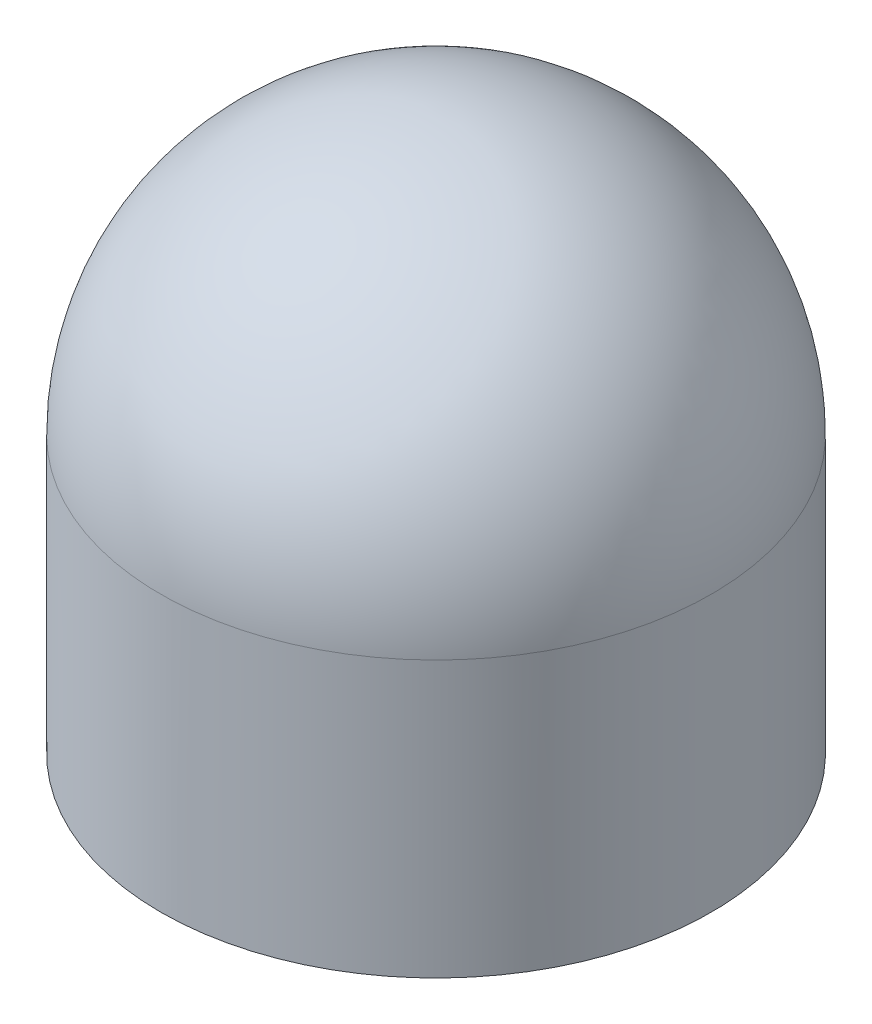
from build123d import *

# Parameters (mm, degrees)
ESQUISSE1_R      = 2.5
EXTRUSION1_DEPTH = 5
CONG_1_R         = 2.5


with BuildPart() as part:
    # Esquisse1 → Extrusion1 (new body)
    with BuildSketch(Plane(origin=(0, 0, 0), x_dir=(1, 0, 0), z_dir=(0, 1, 0))):
        Circle(ESQUISSE1_R)
    extrude(amount=EXTRUSION1_DEPTH)

    # Congé1
    cong_1_edges = [part.edges().sort_by_distance(p)[0] for p in [
        (-2.5, 5, 0),
    ]]
    fillet(cong_1_edges, radius=CONG_1_R)


solid = part.part
